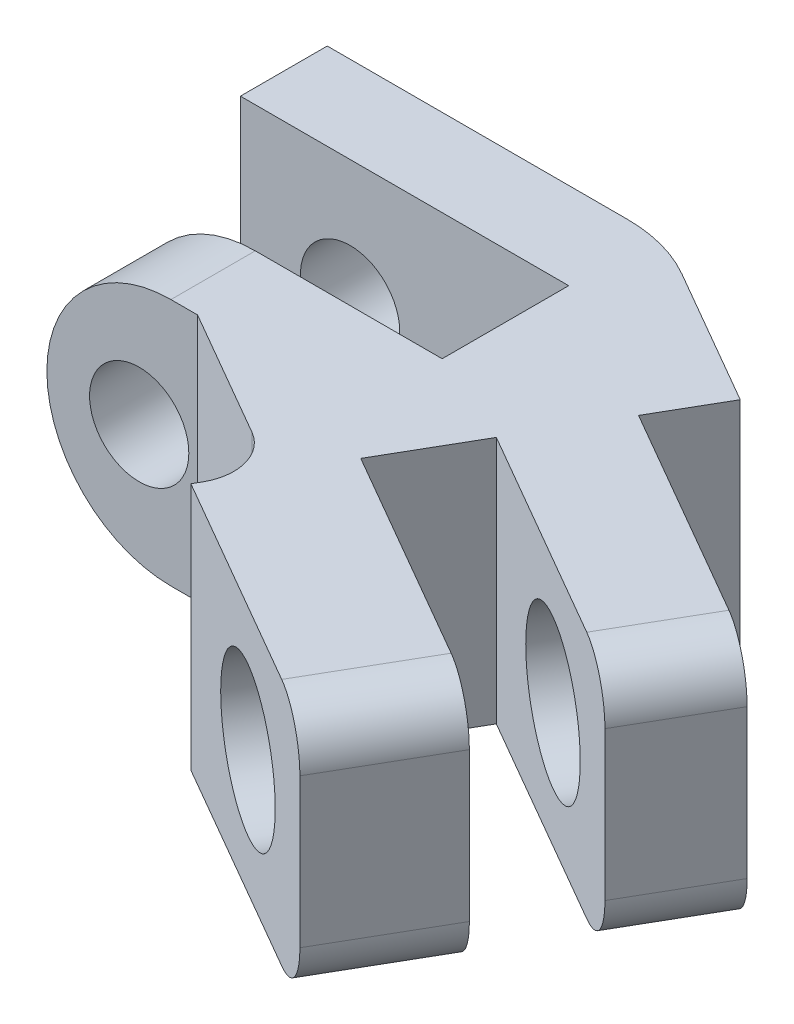
from build123d import *

# Parameters (mm, degrees)
SKETCH_1_R               = 2.5
EXTRUDE_1_DEPTH          = 6
SKETCH_2_W               = 4
SKETCH_2_H               = 5
EXTRUDE_2_DEPTH          = 6
SKETCH_13_W              = 5
SKETCH_13_H              = 10
EXTRUDE_4_DEPTH          = 5
EXTRUDE_4_DEPTH_BACK     = 4.598076
SKETCH_14_W              = 5
SKETCH_14_H              = 5.9776452
CUT_EXTRUDE_6_DEPTH      = 1
CUT_EXTRUDE_6_DEPTH_BACK = 1
SKETCH_5_R               = 1
CUT_EXTRUDE_2_DEPTH      = 7
CUT_EXTRUDE_3_DEPTH      = 1.3
CUT_EXTRUDE_3_DEPTH_BACK = 1.25
SKETCH_17_W              = 2.669872981
SKETCH_17_H              = 5
CUT_EXTRUDE_8_DEPTH      = 4
FILLET_1_R               = 1
FILLET_2_R               = 3
SKETCH_15_R              = 1.5
CUT_EXTRUDE_7_DEPTH      = 5.330126966
CUT_EXTRUDE_7_DEPTH_BACK = 15.778684177
FILLET_3_R               = 1
EXTRUDE_5_DEPTH          = 1.75
SKETCH_18_W              = 6.370272001
SKETCH_18_H              = 5.288650256
CUT_EXTRUDE_9_DEPTH      = 1.5
CUT_EXTRUDE_10_DEPTH     = 1.5


with BuildPart() as part:
    # Sketch 1 → Extrude 1 (new body)
    with BuildSketch(Plane.XY):
        Circle(SKETCH_1_R)
    extrude(amount=EXTRUDE_1_DEPTH)

    # Sketch 2 → Extrude 2 (add)
    with BuildSketch(Plane(origin=(0, 0, 0), x_dir=(-1, 0, 0), z_dir=(0, 0, -1))):
        with Locations((-2, 0)):
            Rectangle(SKETCH_2_W, SKETCH_2_H)
    extrude(amount=-EXTRUDE_2_DEPTH)

    # Sketch 13 → Extrude 4 (add, two sides)
    with BuildSketch(Plane(origin=(-1.299038106, 0, 2.25), x_dir=(0, -1, 0), z_dir=(-0.5, 0, 0.866025404))) as extrude_4_sk:
        with Locations((0, 8.464101615)):
            Rectangle(SKETCH_13_W, SKETCH_13_H)
    extrude(amount=EXTRUDE_4_DEPTH)
    extrude(extrude_4_sk.sketch, amount=-EXTRUDE_4_DEPTH_BACK)

    # Sketch 14 → Cut-Extrude 6 (cut, two sides)
    with BuildSketch(Plane(origin=(-1.299038106, 0, 2.25), x_dir=(0, -1, 0), z_dir=(-0.5, 0, 0.866025404))) as cut_extrude_6_sk:
        with Locations((0, 10.475279015)):
            Rectangle(SKETCH_14_W, SKETCH_14_H)
    extrude(amount=CUT_EXTRUDE_6_DEPTH, mode=Mode.SUBTRACT)
    extrude(cut_extrude_6_sk.sketch, amount=-CUT_EXTRUDE_6_DEPTH_BACK, mode=Mode.SUBTRACT)

    # Sketch 5 → Cut-Extrude 2 (cut, through all)
    with BuildSketch(Plane.XY.offset(6)):
        with Locations((-0.639695784, 0)):
            Circle(SKETCH_5_R)
    extrude(amount=-CUT_EXTRUDE_2_DEPTH, mode=Mode.SUBTRACT)

    # Sketch 6 → Cut-Extrude 3 (cut, two sides)
    with BuildSketch(Plane.XY.offset(3)) as cut_extrude_3_sk:
        with BuildLine():
            Line((3.765698608, 2.5), (0, 2.5))
            ThreePointArc((0, 2.5), (-2.5, 0), (0, -2.5))
            Line((0, -2.5), (3.765698608, -2.5))
            Line((3.765698608, -2.5), (3.765698608, 2.5))
        make_face()
    extrude(amount=CUT_EXTRUDE_3_DEPTH, mode=Mode.SUBTRACT)
    extrude(cut_extrude_3_sk.sketch, amount=-CUT_EXTRUDE_3_DEPTH_BACK, mode=Mode.SUBTRACT)

    # Sketch 17 → Cut-Extrude 8 (cut)
    with BuildSketch(Plane(origin=(3, 0, 1.732050808), x_dir=(-0.5, 0, 0.866025404), z_dir=(-0.866025404, 0, -0.5))):
        with Locations((6.26313972, 0)):
            Rectangle(SKETCH_17_W, SKETCH_17_H)
    extrude(amount=-CUT_EXTRUDE_8_DEPTH, mode=Mode.SUBTRACT)

    # Fillet 1
    fillet_1_edges = [part.edges().sort_by_distance(p)[0] for p in [
        (2.665063509, 0, 10.312177826),
        (4, 0, 8),
    ]]
    fillet(fillet_1_edges, radius=FILLET_1_R)

    # Fillet 2
    fillet_2_edges = [part.edges().sort_by_distance(p)[0] for p in [
        (4, 0, 0),
    ]]
    fillet(fillet_2_edges, radius=FILLET_2_R)

    # Sketch 15 → Cut-Extrude 7 (cut, two sides)
    with BuildSketch(Plane(origin=(1, 0, -1.732050808), x_dir=(-0.866025404, 0, -0.5), z_dir=(0.5, 0, -0.866025404))) as cut_extrude_7_sk:
        with Locations((-10.605683392, 0)):
            Circle(SKETCH_15_R)
    extrude(amount=CUT_EXTRUDE_7_DEPTH, mode=Mode.SUBTRACT)
    extrude(cut_extrude_7_sk.sketch, amount=-CUT_EXTRUDE_7_DEPTH_BACK, mode=Mode.SUBTRACT)

    # Fillet 3
    fillet_3_edges = [part.edges().sort_by_distance(p)[0] for p in [
        (8.861215932, 2.5, 11.580127019),
        (8.861215932, -2.5, 11.580127019),
        (11.760734932, -2.5, 6.558012793),
        (11.760734932, 2.5, 6.558012793),
    ]]
    fillet(fillet_3_edges, radius=FILLET_3_R)

    # Sketch 16 → Extrude 5 (add)
    with BuildSketch(Plane(origin=(0, 0, 0), x_dir=(-1, 0, 0), z_dir=(0, 0, -1))):
        with BuildLine():
            Line((0, 2.5), (2.85, 2.5))
            Line((2.85, 2.5), (2.85, -2.5))
            Line((2.85, -2.5), (0, -2.5))
            ThreePointArc((0, -2.5), (2.5, 0), (0, 2.5))
        make_face()
    extrude(amount=-EXTRUDE_5_DEPTH)

    # Sketch 18 → Cut-Extrude 9 (cut)
    with BuildSketch(Plane(origin=(-3.799038106, 0, 6.580127019), x_dir=(0.866025404, 0, 0.5), z_dir=(-0.5, 0, 0.866025404))):
        with Locations((10.278965615, -0.144325128)):
            Rectangle(SKETCH_18_W, SKETCH_18_H)
    extrude(amount=-CUT_EXTRUDE_9_DEPTH, mode=Mode.SUBTRACT)

    # Sketch 19 → Cut-Extrude 10 (cut)
    with BuildSketch(Plane(origin=(1, 0, -1.732050808), x_dir=(-0.866025404, 0, -0.5), z_dir=(0.5, 0, -0.866025404))):
        with BuildLine():
            Line((-13.464101615, 1.5), (-13.464101615, -1.5))
            ThreePointArc((-13.464101615, -1.5), (-13.171208396, -2.207106781), (-12.464101615, -2.5))
            Line((-12.464101615, -2.5), (-7.486456415, -2.5))
            Line((-7.486456415, -2.5), (-7.486456415, 2.5))
            Line((-7.486456415, 2.5), (-12.464101615, 2.5))
            ThreePointArc((-12.464101615, 2.5), (-13.171208396, 2.207106781), (-13.464101615, 1.5))
        make_face()
    extrude(amount=-CUT_EXTRUDE_10_DEPTH, mode=Mode.SUBTRACT)


solid = part.part
